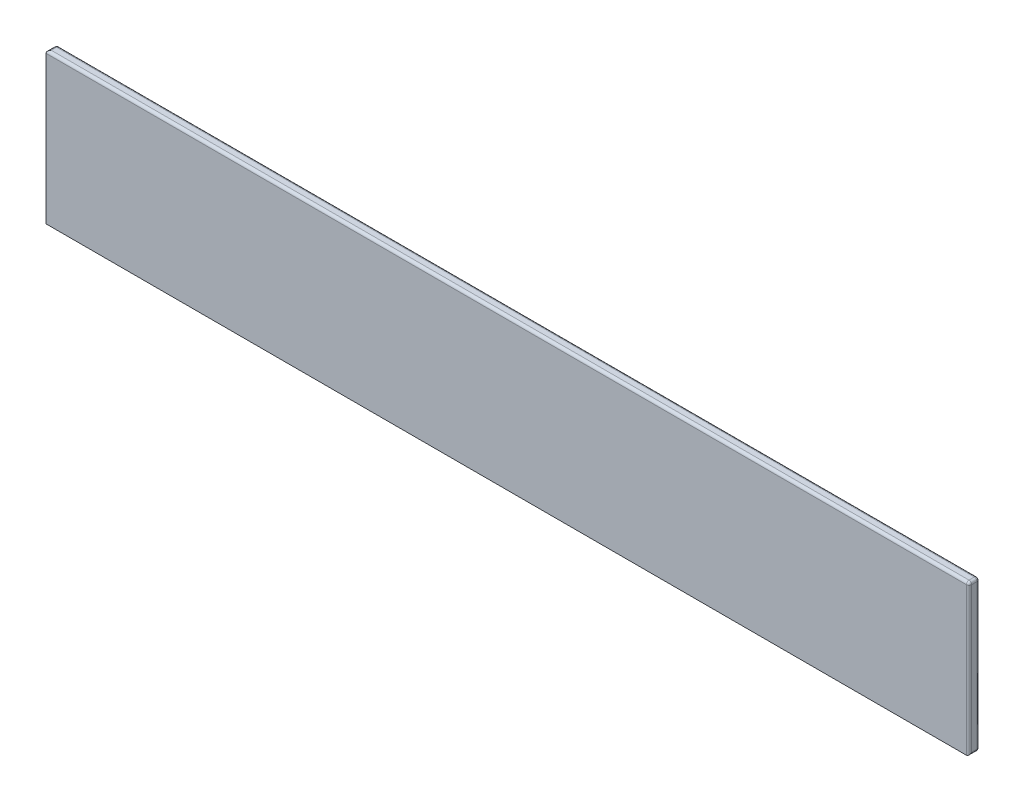
from build123d import *

# Parameters (mm, degrees)
SKETCH1_W           = 1750
SKETCH1_H           = 285
BOSS_EXTRUDE1_DEPTH = 20
FILLET1_R           = 5


with BuildPart() as part:
    # Sketch1 → Boss-Extrude1 (new body)
    with BuildSketch(Plane.XY):
        Rectangle(SKETCH1_W, SKETCH1_H)
    extrude(amount=BOSS_EXTRUDE1_DEPTH)

    # Fillet1
    fillet1_edges = [part.edges().sort_by_distance(p)[0] for p in [
        (875, 0, 20),
        (0, -142.5, 0),
        (-875, 0, 0),
        (0, 142.5, 0),
        (875, 0, 0),
        (875, -142.5, 10),
        (-875, 142.5, 10),
        (875, 142.5, 10),
        (0, 142.5, 20),
    ]]
    fillet(fillet1_edges, radius=FILLET1_R)


solid = part.part
